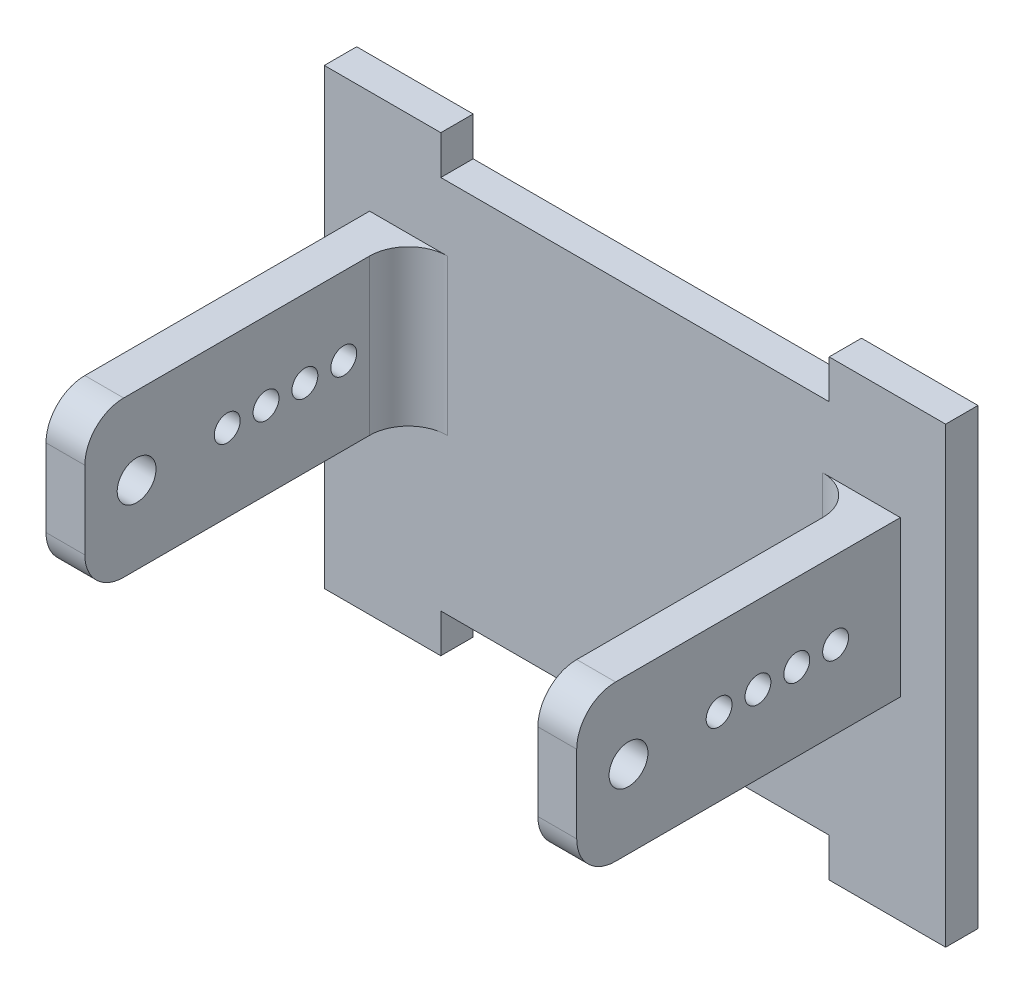
from build123d import *

# Parameters (mm, degrees)
BOSS_EXTRU_1_DEPTH      = 2.5
ESQUISSE2_W             = 3
ESQUISSE2_H             = 12
BOSS_EXTRU_2_DEPTH      = 25
ESQUISSE3_R             = 1
ESQUISSE3_R_2           = 1.5
ENL_V_MAT_EXTRU_1_DEPTH = 50
CONG_1_R                = 3
CONG_2_R                = 3


with BuildPart() as part:
    # Esquisse1 → Boss.-Extru.1 (new body)
    with BuildSketch(Plane.XY):
        Polygon((39, 35), (48, 35), (48, 0), (39, 0), (39, 3), (9, 3), (9, 0), (0, 0), (0, 35), (9, 35), (9, 32), (39, 32), align=None)
    extrude(amount=BOSS_EXTRU_1_DEPTH)

    # Esquisse2 → Boss.-Extru.2 (add)
    with BuildSketch(Plane.XY.offset(2.5)):
        with Locations((5, 21)):
            Rectangle(ESQUISSE2_W, ESQUISSE2_H)
        with Locations((43, 21)):
            Rectangle(ESQUISSE2_W, ESQUISSE2_H)
    extrude(amount=BOSS_EXTRU_2_DEPTH)

    # Esquisse3 → Enlèv. mat.-Extru.1 (cut)
    with BuildSketch(Plane(origin=(44.5, 0, 0), x_dir=(0, 0, -1), z_dir=(1, 0, 0))):
        with Locations((-7.5, 21)):
            Circle(ESQUISSE3_R)
        with Locations((-10.5, 21)):
            Circle(ESQUISSE3_R)
        with Locations((-13.5, 21)):
            Circle(ESQUISSE3_R)
        with Locations((-16.5, 21)):
            Circle(ESQUISSE3_R)
        with Locations((-23.5, 21)):
            Circle(ESQUISSE3_R_2)
    extrude(amount=-ENL_V_MAT_EXTRU_1_DEPTH, mode=Mode.SUBTRACT)

    # Congé1
    cong_1_edges = [part.edges().sort_by_distance(p)[0] for p in [
        (5, 15, 27.5),
        (5, 27, 27.5),
        (43, 15, 27.5),
        (43, 27, 27.5),
    ]]
    fillet(cong_1_edges, radius=CONG_1_R)

    # Congé2
    cong_2_edges = [part.edges().sort_by_distance(p)[0] for p in [
        (6.5, 21, 2.5),
        (41.5, 21, 2.5),
    ]]
    fillet(cong_2_edges, radius=CONG_2_R)


solid = part.part
